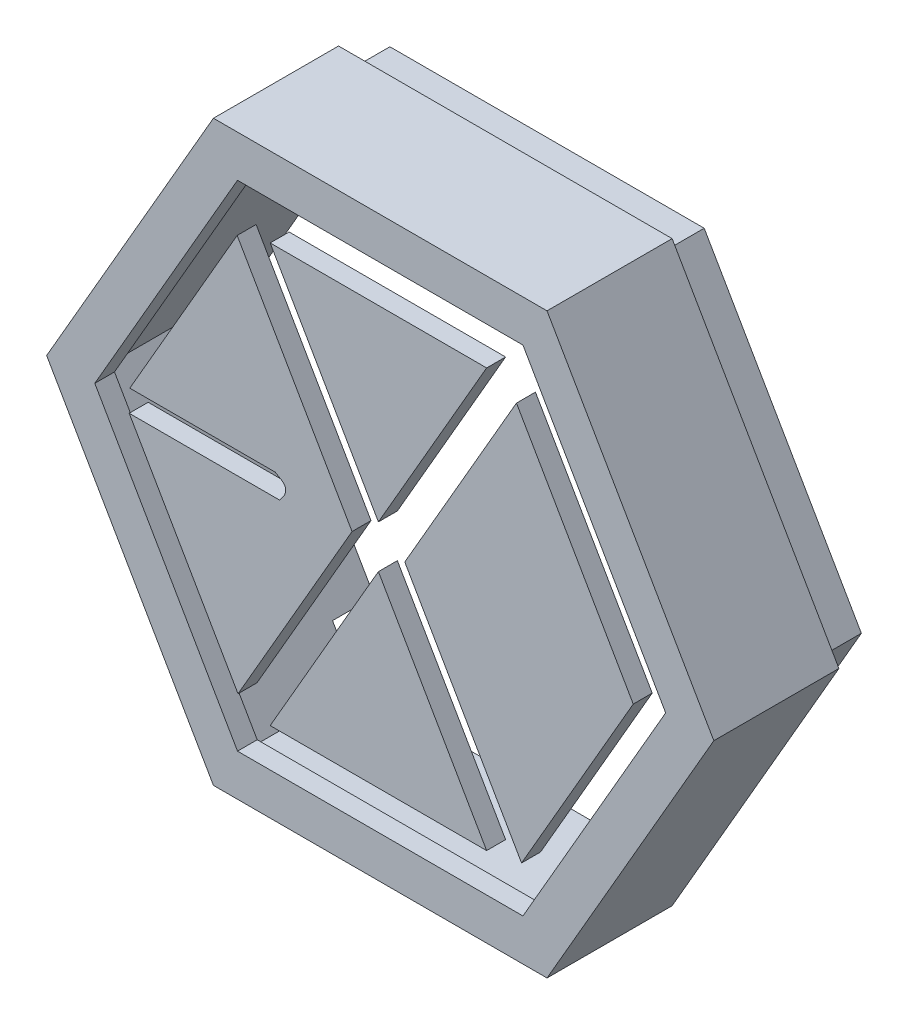
from build123d import *

# Parameters (mm, degrees)
BOSS_EXTRUDE1_DEPTH   = 50.8
BOSS_EXTRUDE1_2_DEPTH = 50.8
BOSS_EXTRUDE1_3_DEPTH = 50.8
BOSS_EXTRUDE1_4_DEPTH = 50.8
SCALE2_SCALE          = 0.056837178
BOSS_EXTRUDE2_DEPTH   = 19.05
BOSS_EXTRUDE3_DEPTH   = 25.4
BOSS_EXTRUDE4_DEPTH   = 3
SKETCH5_W             = 76.2
SKETCH5_H             = 6.35
CUT_EXTRUDE1_DEPTH    = 12.7


with BuildPart() as part:
    # Sketch1 → Boss-Extrude1 (new body)
    with BuildSketch(Plane.XY):
        Polygon((700.771920951, 1351.480504637), (1280.771920951, 1351.480504637), (990.771920951, 849.185770443), align=None)
    extrude(amount=-BOSS_EXTRUDE1_DEPTH)


with BuildPart() as body_2:
    # Sketch1 → Boss-Extrude1 2 (new body)
    with BuildSketch(Plane.XY):
        with BuildLine():
            Line((612.319771216, 1324.684122016), (920.139059743, 791.525474739))
            Line((920.139059743, 791.525474739), (614.639059743, 262.383953026))
            Line((614.639059743, 262.383953026), (323.040465784, 767.447533178))
            Line((323.040465784, 767.447533178), (726.261001344, 767.447533178))
            add(Edge.make_bspline(
                [(726.261001344, 767.447533178), (731.261001344, 775.447533178), (738.972924833, 782.295227136), (741.261001344, 791.447533178), (746.676940536, 813.111289947), (727.862395623, 817.577058647), (714.261001344, 826.447533178)],
                knots=[0, 0, 0, 0, 1, 1, 1, 2, 2, 2, 2], degree=3))
            Line((714.261001344, 826.447533178), (324.66274253, 826.447533178))
            Line((324.66274253, 826.447533178), (612.319771216, 1324.684122016))
        make_face()
    extrude(amount=-BOSS_EXTRUDE1_2_DEPTH)


with BuildPart() as body_3:
    # Sketch1 → Boss-Extrude1 3 (new body)
    with BuildSketch(Plane.XY):
        Polygon((1360.681295443, 1309.887601259), (1673.580097254, 767.930978895), (1374.30358397, 249.568852374), (1061.404782158, 791.525474739), align=None)
    extrude(amount=-BOSS_EXTRUDE1_3_DEPTH)


with BuildPart() as body_4:
    # Sketch1 → Boss-Extrude1 4 (new body)
    with BuildSketch(Plane.XY):
        Polygon((990.771920951, 733.865179035), (1280.771920951, 231.57044484), (700.771920951, 231.57044484), align=None)
    extrude(amount=-BOSS_EXTRUDE1_4_DEPTH)


with BuildPart() as part_1:
    # Scale2: scaled about (0, 0, 0)
    add(part.part.scale(SCALE2_SCALE))


with BuildPart() as body_2_1:
    # Scale2: scaled about (0, 0, 0)
    add(body_2.part.scale(SCALE2_SCALE))


with BuildPart() as body_4_1:
    # Scale2: scaled about (0, 0, 0)
    add(body_4.part.scale(SCALE2_SCALE))


with BuildPart() as body_3_1:
    # Scale2: scaled about (0, 0, 0)
    add(body_3.part.scale(SCALE2_SCALE))


with BuildPart() as body_5:
    # Sketch2 → Boss-Extrude2 (new body)
    with BuildSketch(Plane.XY):
        Polygon((107.391144765, 44.94876217), (81.991144765, 88.942852683), (31.191144765, 88.942852683), (5.791144765, 44.94876217), (31.191144765, 0.954671658), (81.991144765, 0.954671658), align=None)
        Polygon((104.458205398, 44.94876217), (80.524675081, 86.402852683), (32.657614449, 86.402852683), (8.724084133, 44.94876217), (32.657614449, 3.494671658), (80.524675081, 3.494671658), align=None, mode=Mode.SUBTRACT)
    extrude(amount=-BOSS_EXTRUDE2_DEPTH)

    # Sketch3 → Boss-Extrude3 (add)
    with BuildSketch(Plane.XY):
        Polygon((104.458205398, 44.94876217), (80.524675081, 86.402852683), (32.657614449, 86.402852683), (8.724084133, 44.94876217), (32.657614449, 3.494671658), (80.524675081, 3.494671658), align=None)
        Polygon((101.52526603, 44.94876217), (79.058205398, 83.862852683), (34.124084133, 83.862852683), (11.6570235, 44.94876217), (34.124084133, 6.034671658), (79.058205398, 6.034671658), align=None, mode=Mode.SUBTRACT)
    extrude(amount=-BOSS_EXTRUDE3_DEPTH)

    # Sketch4 → Boss-Extrude4 (add)
    with BuildSketch(Plane.XY):
        Polygon((101.52526603, 44.94876217), (79.058205398, 83.862852683), (34.124084133, 83.862852683), (11.6570235, 44.94876217), (34.124084133, 6.034671658), (79.058205398, 6.034671658), align=None)
        Polygon((100.058796346, 44.94876217), (78.324970556, 82.592852683), (34.857318974, 82.592852683), (13.123493184, 44.94876217), (34.857318974, 7.304671658), (78.324970556, 7.304671658), align=None, mode=Mode.SUBTRACT)
    extrude(amount=-BOSS_EXTRUDE4_DEPTH)

    # Sketch5 → Cut-Extrude1 (cut)
    with BuildSketch(Plane(origin=(0, 0, 0), x_dir=(1, 0, 0), z_dir=(0, 1, 0))):
        with Locations((56.591144765, 22.225)):
            Rectangle(SKETCH5_W, SKETCH5_H)
    extrude(amount=CUT_EXTRUDE1_DEPTH, mode=Mode.SUBTRACT)


solid = Compound([part_1.part, body_2_1.part, body_4_1.part, body_3_1.part, body_5.part])
